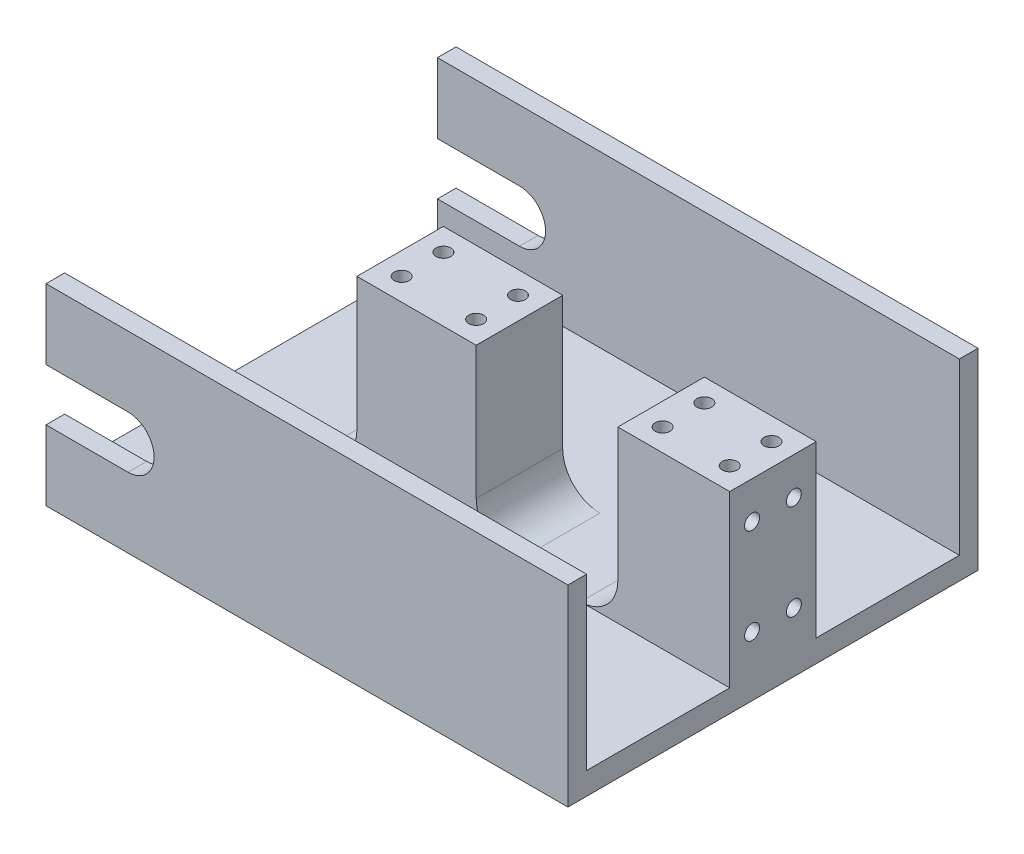
from build123d import *

# Parameters (mm, degrees)
SKETCH1_W           = 70
SKETCH1_H           = 3
BOSS_EXTRUDE1_DEPTH = 55
SKETCH2_W           = 70
SKETCH2_H           = 2.5
BOSS_EXTRUDE2_DEPTH = 22.8
SKETCH5_R           = 3.5
CUT_EXTRUDE1_DEPTH  = 84.8
SKETCH6_W           = 16
SKETCH6_H           = 11.6
SKETCH6_W_2         = 15
BOSS_EXTRUDE7_DEPTH = 22.8
SKETCH7_R           = 1
CUT_EXTRUDE2_DEPTH  = 8
SKETCH8_R           = 1
CUT_EXTRUDE3_DEPTH  = 8
FILLET1_R           = 5
SKETCH9_W           = 14.084433838
SKETCH9_H           = 7
CUT_EXTRUDE4_DEPTH  = 66


with BuildPart() as part:
    # Sketch1 → Boss-Extrude1 (new body)
    with BuildSketch(Plane.XY):
        Rectangle(SKETCH1_W, SKETCH1_H)
    extrude(amount=BOSS_EXTRUDE1_DEPTH)

    # Sketch2 → Boss-Extrude2 (add)
    with BuildSketch(Plane(origin=(0, 1.5, 0), x_dir=(1, 0, 0), z_dir=(0, 1, 0))):
        with Locations((0, -1.25)):
            Rectangle(SKETCH2_W, SKETCH2_H)
        with Locations((0, -53.75)):
            Rectangle(SKETCH2_W, SKETCH2_H)
    extrude(amount=BOSS_EXTRUDE2_DEPTH)

    # Sketch5 → Cut-Extrude1 (cut)
    with BuildSketch(Plane.XY.offset(55)):
        with Locations((-24, 11.4)):
            Circle(SKETCH5_R)
    extrude(amount=-CUT_EXTRUDE1_DEPTH, mode=Mode.SUBTRACT)

    # Sketch6 → Boss-Extrude7 (add)
    with BuildSketch(Plane(origin=(0, 24.3, 0), x_dir=(1, 0, 0), z_dir=(0, 1, 0))):
        with Locations((-7, -27.5)):
            Rectangle(SKETCH6_W, SKETCH6_H)
        with Locations((27.5, -27.5)):
            Rectangle(SKETCH6_W_2, SKETCH6_H)
    extrude(amount=-BOSS_EXTRUDE7_DEPTH)

    # Sketch7 → Cut-Extrude2 (cut)
    with BuildSketch(Plane(origin=(0, 24.3, 0), x_dir=(1, 0, 0), z_dir=(0, 1, 0))):
        with Locations((-12, -24.7)):
            Circle(SKETCH7_R)
        with Locations((23, -30.3)):
            Circle(SKETCH7_R)
        with Locations((-2, -24.7)):
            Circle(SKETCH7_R)
        with Locations((-2, -30.3)):
            Circle(SKETCH7_R)
        with Locations((-12, -30.3)):
            Circle(SKETCH7_R)
        with Locations((23, -24.7)):
            Circle(SKETCH7_R)
        with Locations((32, -24.7)):
            Circle(SKETCH7_R)
        with Locations((32, -30.3)):
            Circle(SKETCH7_R)
    extrude(amount=-CUT_EXTRUDE2_DEPTH, mode=Mode.SUBTRACT)

    # Sketch8 → Cut-Extrude3 (cut)
    with BuildSketch(Plane(origin=(35, 0, 0), x_dir=(0, 0, -1), z_dir=(1, 0, 0))):
        with Locations((-24.7, 19.3)):
            Circle(SKETCH8_R)
        with Locations((-30.3, 19.3)):
            Circle(SKETCH8_R)
        with Locations((-24.7, 6.5)):
            Circle(SKETCH8_R)
        with Locations((-30.3, 6.5)):
            Circle(SKETCH8_R)
    extrude(amount=-CUT_EXTRUDE3_DEPTH, mode=Mode.SUBTRACT)

    # Fillet1
    fillet1_edges = [part.edges().sort_by_distance(p)[0] for p in [
        (1, 1.5, 27.5),
        (-15, 1.5, 27.5),
        (20, 1.5, 27.5),
    ]]
    fillet(fillet1_edges, radius=FILLET1_R)

    # Sketch9 → Cut-Extrude4 (cut)
    with BuildSketch(Plane.XY.offset(55)):
        with Locations((-31.042216919, 11.4)):
            Rectangle(SKETCH9_W, SKETCH9_H)
    extrude(amount=-CUT_EXTRUDE4_DEPTH, mode=Mode.SUBTRACT)


solid = part.part
